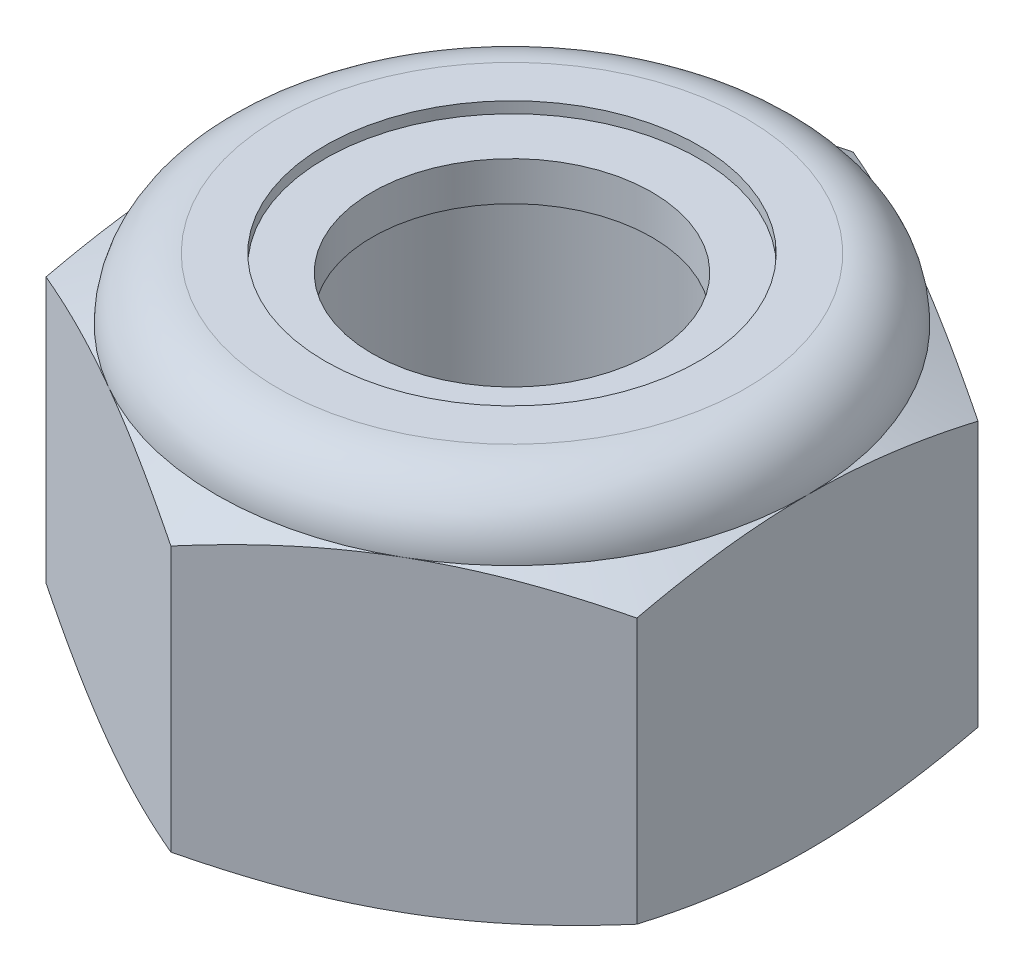
from build123d import *

# Parameters (mm, degrees)
EXTRUDE1_DEPTH = 5
SKETCH2_W      = 2.5
SKETCH2_H      = 5


with BuildPart() as part:
    # Sketch1 → Extrude1 (new body)
    with BuildSketch(Plane(origin=(0, 0, 0), x_dir=(1, 0, 0), z_dir=(0, 1, 0))):
        Polygon((0, 4.618802154), (-4, 2.309401077), (-4, -2.309401077), (0, -4.618802154), (4, -2.309401077), (4, 2.309401077), align=None)
    extrude(amount=EXTRUDE1_DEPTH)


with BuildPart() as body_2:
    # Sketch2 → Revolve1 (revolve)
    with BuildSketch(Plane(origin=(0, 0, 0), x_dir=(0, 0, -1), z_dir=(1, 0, 0))):
        with Locations((1.25, 2.5)):
            Rectangle(SKETCH2_W, SKETCH2_H)
    revolve(axis=Axis((0, -2.5, 0), (0, 1, 0)))

    # Boss-Extrude1 cone 1 section (through the dimple's axis) → Boss-Extrude1 (revolve)
    with BuildSketch(Plane(origin=(0, 0, 0), x_dir=(0, 0, -1), z_dir=(1, 0, 0))):
        Polygon((0, 0), (2.5, 0), (0, 2.5), align=None)
    revolve(axis=Axis((0, 0, 0), (0, 1, 0)))

    # Boss-Extrude2 cone 1 section (through the dimple's axis) → Boss-Extrude2 (revolve)
    with BuildSketch(Plane(origin=(0, 5, 0), x_dir=(0, 0, 1), z_dir=(1, 0, 0))):
        Polygon((0, 0), (2.5, 0), (0, 2.5), align=None)
    revolve(axis=Axis((0, 5, 0), (0, -1, 0)))


with BuildPart() as part_1:
    add(part.part)

    # Combine1: cut body 2
    add(body_2.part, mode=Mode.SUBTRACT)

    # Sketch5 → Cut-Revolve3 (revolve, cut)
    with BuildSketch(Plane(origin=(0, 0, 0), x_dir=(0, 0, -1), z_dir=(1, 0, 0))):
        with BuildLine():
            Line((0, 0), (4, 0))
            Line((4, 0), (4.618802154, 0.288552183))
            Line((4.618802154, 0.288552183), (4.618802154, 3.878114484))
            Line((4.618802154, 3.878114484), (4, 4.166666667))
            ThreePointArc((4, 4.166666667), (3.755922318, 4.755922318), (3.166666667, 5))
            Line((3.166666667, 5), (3.166666667, 6.27))
            Line((3.166666667, 6.27), (5.888802154, 6.27))
            Line((5.888802154, 6.27), (5.888802154, -1.27))
            Line((5.888802154, -1.27), (0, -1.27))
            Line((0, -1.27), (0, 0))
        make_face()
    revolve(axis=Axis((0, 0, 0), (0, 1, 0)), mode=Mode.SUBTRACT)

    # Sketch6 → Cut-Revolve4 (revolve, cut)
    with BuildSketch(Plane(origin=(0, 0, 0), x_dir=(0, 0, -1), z_dir=(1, 0, 0)), mode=Mode.PRIVATE) as cut_revolve4_sk:
        with BuildLine():
            Line((0, 4.166666667), (3.8476, 4.166666667))
            ThreePointArc((3.8476, 4.166666667), (3.648159244, 4.648159244), (3.166666667, 4.8476))
            Line((3.166666667, 4.8476), (2.530224442, 4.8476))
            Line((2.530224442, 4.8476), (2.530224442, 6.27))
            Line((2.530224442, 6.27), (0, 6.27))
            Line((0, 6.27), (0, 4.166666667))
        make_face()
    revolve(cut_revolve4_sk.sketch.rotate(Axis((0, 6.27, 0), (0, -1, 0)), 180), axis=Axis((0, 6.27, 0), (0, -1, 0)), mode=Mode.SUBTRACT)


with BuildPart() as body_2_2:
    # Sketch7 → Revolve2 (revolve)
    with BuildSketch(Plane(origin=(0, 0, 0), x_dir=(0, 0, -1), z_dir=(1, 0, 0))):
        with BuildLine():
            Line((1.893782217, 4.242866667), (3.766579964, 4.242866667))
            ThreePointArc((3.766579964, 4.242866667), (3.566430175, 4.620419399), (3.166666667, 4.7714))
            Line((3.166666667, 4.7714), (1.893782217, 4.7714))
            Line((1.893782217, 4.7714), (1.893782217, 4.242866667))
        make_face()
    revolve(axis=Axis((0, 4.242866667, 0), (0, 1, 0)))


solid = Compound([part_1.part, body_2_2.part])
